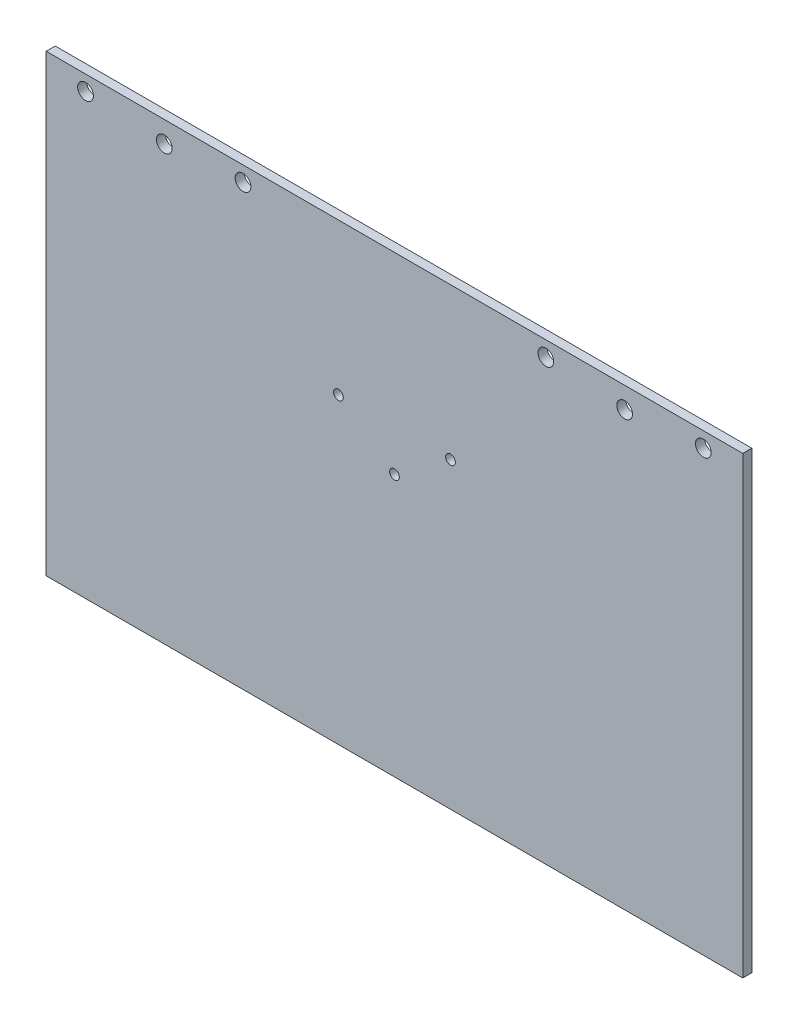
from build123d import *

# Parameters (mm, degrees)
SKETCH_1_W          = 230
SKETCH_1_H          = 150
EXTRUDE_1_DEPTH     = 3
SKETCH_7_R          = 2.6
CUT_EXTRUDE_4_DEPTH = 10
SKETCH1_R           = 1.6
CUT_EXTRUDE1_DEPTH  = 10


with BuildPart() as part:
    # 草图1 → 凸台-拉伸1 (new body)
    with BuildSketch(Plane.XY):
        with Locations((-30, 25)):
            Rectangle(SKETCH_1_W, SKETCH_1_H)
    extrude(amount=EXTRUDE_1_DEPTH)

    # 草图7 → 切除-拉伸4 (cut)
    with BuildSketch(Plane(origin=(0, 0, 0), x_dir=(-1, 0, 0), z_dir=(0, 0, -1))):
        with Locations((-20, 95)):
            Circle(SKETCH_7_R)
        with Locations((-72, 95)):
            Circle(SKETCH_7_R)
        with Locations((-46, 93)):
            Circle(SKETCH_7_R)
        with Locations((132, 95)):
            Circle(SKETCH_7_R)
        with Locations((106, 93)):
            Circle(SKETCH_7_R)
        with Locations((80, 95)):
            Circle(SKETCH_7_R)
    extrude(amount=-CUT_EXTRUDE_4_DEPTH, mode=Mode.SUBTRACT)

    # Sketch1 → Cut-Extrude1 (cut)
    with BuildSketch(Plane.XY.offset(3)):
        with Locations((-30, 36.5)):
            Circle(SKETCH1_R)
        with Locations((-11.5, 50)):
            Circle(SKETCH1_R)
        with Locations((-48.5, 50)):
            Circle(SKETCH1_R)
    extrude(amount=-CUT_EXTRUDE1_DEPTH, mode=Mode.SUBTRACT)


solid = part.part
